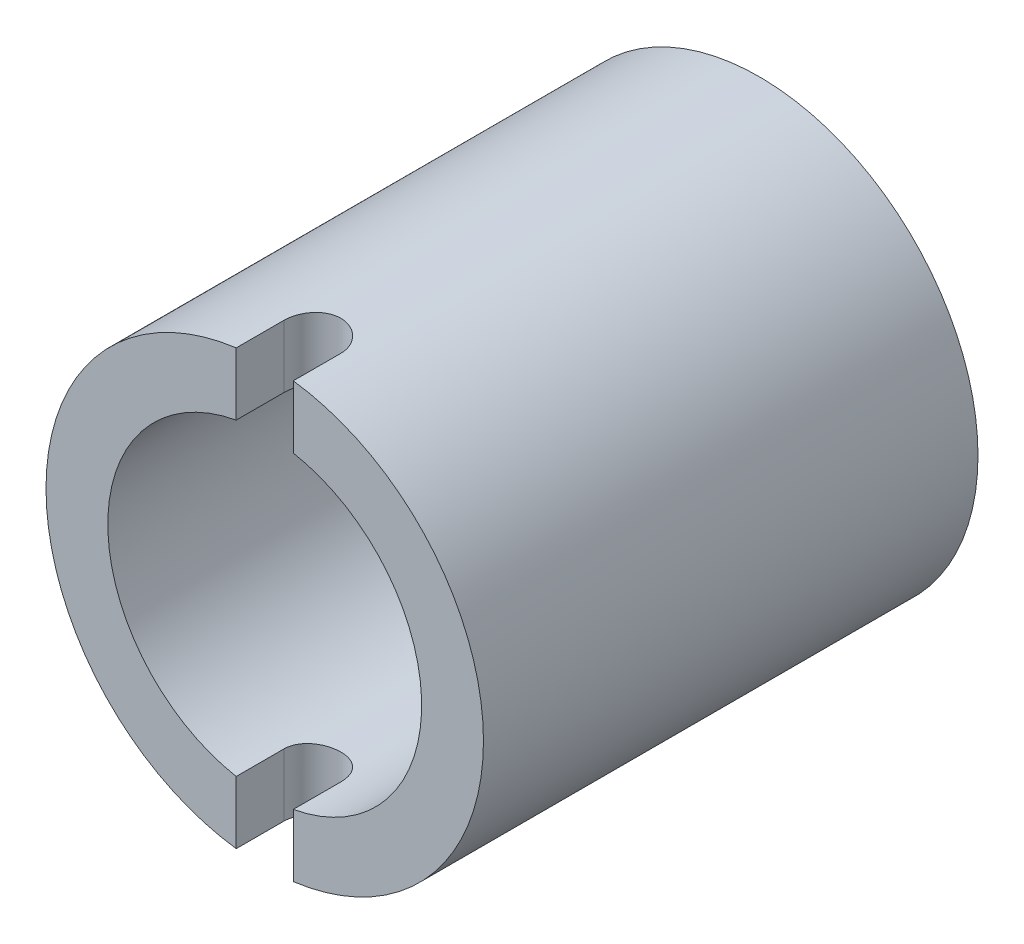
from build123d import *

# Parameters (mm, degrees)
SKETCH1_R               = 9.128125
SKETCH1_R_2             = 6.5484375
EXTRUDE1_DEPTH          = 20.6375
CUT_EXTRUDE1_DEPTH      = 10.128125
CUT_EXTRUDE1_DEPTH_BACK = 10.128125


with BuildPart() as part:
    # Sketch1 → Extrude1 (new body)
    with BuildSketch(Plane.XY):
        Circle(SKETCH1_R)
        Circle(SKETCH1_R_2, mode=Mode.SUBTRACT)
    extrude(amount=EXTRUDE1_DEPTH)

    # Sketch2 → Cut-Extrude1 (cut, two sides)
    with BuildSketch(Plane(origin=(0, 0, 0), x_dir=(1, 0, 0), z_dir=(0, 1, 0))) as cut_extrude1_sk:
        with BuildLine():
            Line((-1.190625, -20.6375), (-1.190625, -18.653125))
            ThreePointArc((-1.190625, -18.653125), (0, -17.4625), (1.190625, -18.653125))
            Line((1.190625, -18.653125), (1.190625, -20.6375))
            Line((1.190625, -20.6375), (-1.190625, -20.6375))
        make_face()
    extrude(amount=CUT_EXTRUDE1_DEPTH, mode=Mode.SUBTRACT)
    extrude(cut_extrude1_sk.sketch, amount=-CUT_EXTRUDE1_DEPTH_BACK, mode=Mode.SUBTRACT)


solid = part.part
